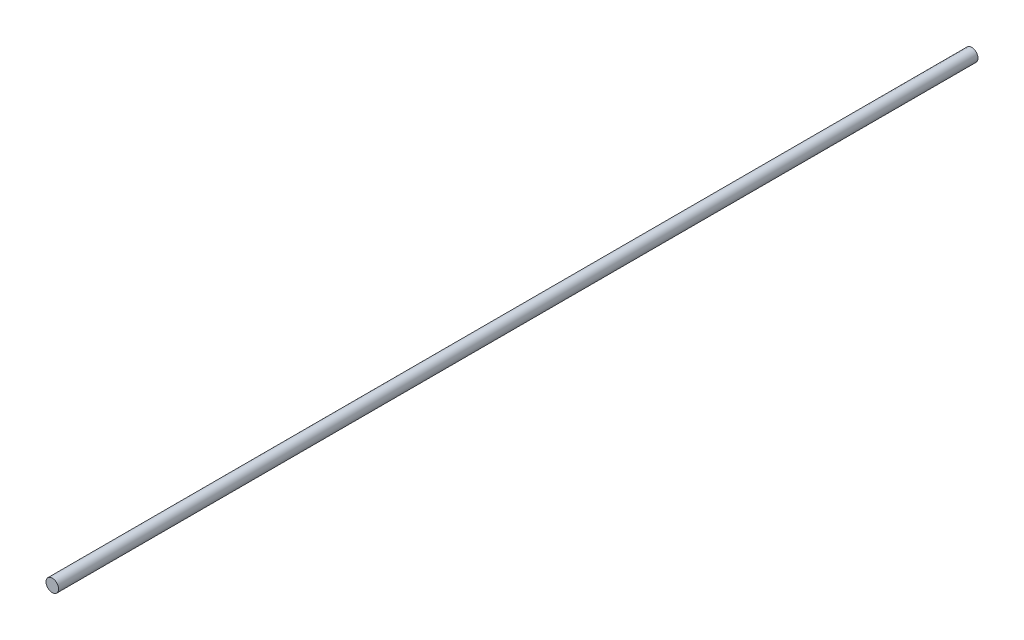
from build123d import *

# Parameters (mm, degrees)
SKETCH1_R           = 1.25
BOSS_EXTRUDE1_DEPTH = 182.2


with BuildPart() as part:
    # Sketch1 → Boss-Extrude1 (new body)
    with BuildSketch(Plane.XY):
        Circle(SKETCH1_R)
    extrude(amount=BOSS_EXTRUDE1_DEPTH)


solid = part.part
